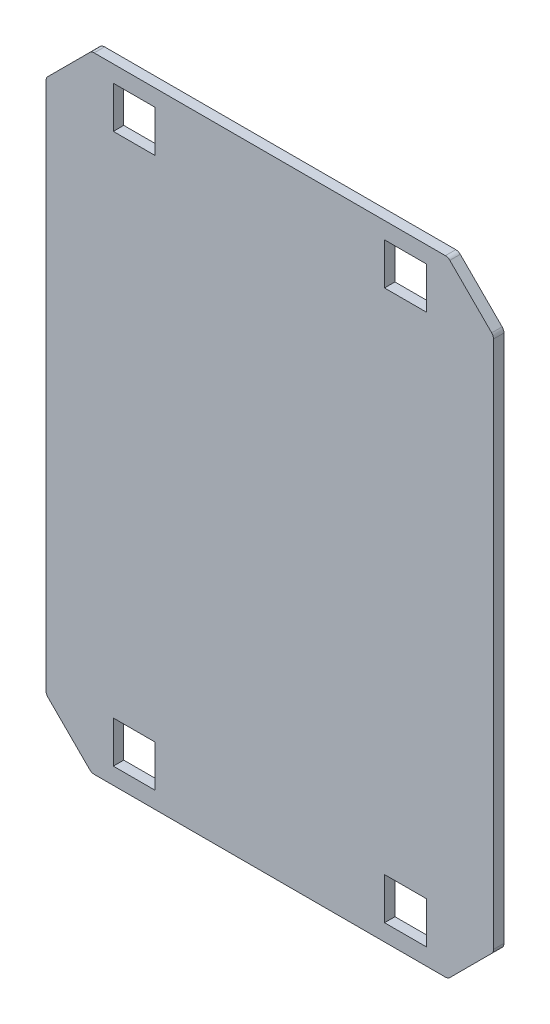
from build123d import *

# Parameters (mm, degrees)
BOSS_EXTRU_1_DEPTH      = 5
ESQUISSE2_W             = 20
ESQUISSE2_H             = 20
ENL_V_MAT_EXTRU_1_DEPTH = 5
ENL_V_MAT_EXTRU_2_DEPTH = 5
CONG_1_R                = 3


with BuildPart() as part:
    # Esquisse1 → Boss.-Extru.1 (new body)
    with BuildSketch(Plane.XY):
        Polygon((-112.248737342, -130), (-87.5, -154.748737342), (87.5, -154.748737342), (112.248737342, -130), (112.248737342, 130), (87.5, 154.748737342), (-87.5, 154.748737342), (-112.248737342, 130), align=None)
    extrude(amount=BOSS_EXTRU_1_DEPTH)

    # Esquisse2 → Enlèv. mat.-Extru.1 (cut)
    with BuildSketch(Plane.XY.offset(5)):
        with Locations((-65, 131.748737342)):
            Rectangle(ESQUISSE2_W, ESQUISSE2_H)
        with Locations((-65, -131.748737342)):
            Rectangle(ESQUISSE2_W, ESQUISSE2_H)
        with Locations((65, -131.748737342)):
            Rectangle(ESQUISSE2_W, ESQUISSE2_H)
        with Locations((65, 131.748737342)):
            Rectangle(ESQUISSE2_W, ESQUISSE2_H)
    extrude(amount=-ENL_V_MAT_EXTRU_1_DEPTH, mode=Mode.SUBTRACT)

    # Esquisse3 → Enlèv. mat.-Extru.2 (cut)
    with BuildSketch(Plane.XY.offset(5)):
        Polygon((-87.5, 154.748737342), (-112.248737342, 130), (-112.248737342, -130), (-87.5, -154.748737342), (87.5, -154.748737342), (112.248737342, -130), (112.248737342, 130), (87.5, 154.748737342), align=None)
        Polygon((-107.248737342, 127.928932188), (-107.248737342, -127.928932188), (-85.428932188, -149.748737342), (85.428932188, -149.748737342), (107.248737342, -127.928932188), (107.248737342, 127.928932188), (85.428932188, 149.748737342), (-85.428932188, 149.748737342), align=None, mode=Mode.SUBTRACT)
    extrude(amount=-ENL_V_MAT_EXTRU_2_DEPTH, mode=Mode.SUBTRACT)

    # Congé1
    cong_1_edges = [part.edges().sort_by_distance(p)[0] for p in [
        (-85.428932188, 149.748737342, 2.5),
        (85.428932188, 149.748737342, 2.5),
        (107.248737342, 127.928932188, 2.5),
        (107.248737342, -127.928932188, 2.5),
        (85.428932188, -149.748737342, 2.5),
        (-85.428932188, -149.748737342, 2.5),
        (-107.248737342, -127.928932188, 2.5),
        (-107.248737342, 127.928932188, 2.5),
    ]]
    fillet(cong_1_edges, radius=CONG_1_R)


solid = part.part
